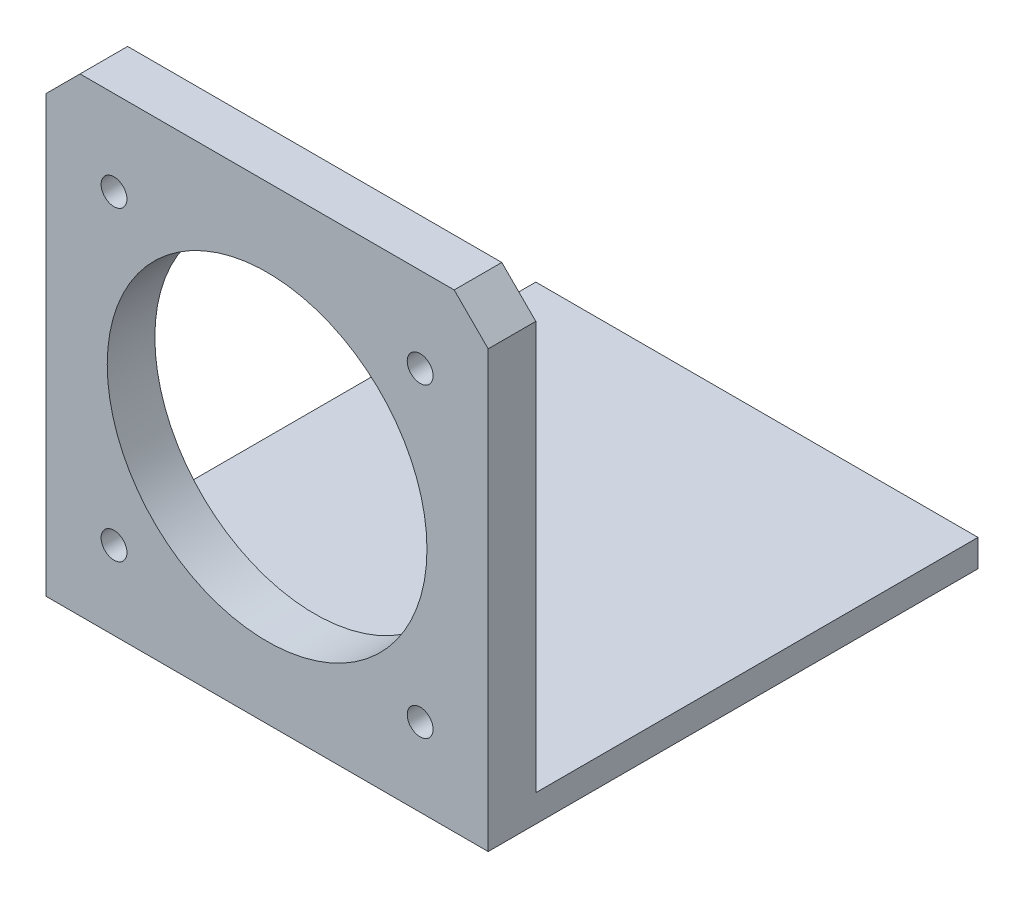
from build123d import *

# Parameters (mm, degrees)
BOSS_EXTRUDE1_DEPTH = 65
CHAMFER1_SIZE       = 5
SKETCH4_R           = 23.5
SKETCH4_R_2         = 1.9
CUT_EXTRUDE1_DEPTH  = 65


with BuildPart() as part:
    # Sketch2 → Boss-Extrude1 (new body)
    with BuildSketch(Plane(origin=(0, 0, 0), x_dir=(0, 0, -1), z_dir=(1, 0, 0))):
        Polygon((0, 0), (0, 65), (-7, 65), (-7, -4), (65, -4), (65, 0), align=None)
    extrude(amount=BOSS_EXTRUDE1_DEPTH)

    # Chamfer1
    chamfer1_edges = [part.edges().sort_by_distance(p)[0] for p in [
        (65, 65, 3.5),
        (0, 65, 3.5),
    ]]
    chamfer(chamfer1_edges, length=CHAMFER1_SIZE)

    # Sketch4 → Cut-Extrude1 (cut)
    with BuildSketch(Plane.XY.offset(7)):
        with Locations((32.5, 30)):
            Circle(SKETCH4_R)
        with Locations((10, 52.5)):
            Circle(SKETCH4_R_2)
        with Locations((55, 52.5)):
            Circle(SKETCH4_R_2)
        with Locations((55, 7.5)):
            Circle(SKETCH4_R_2)
        with Locations((10, 7.5)):
            Circle(SKETCH4_R_2)
    extrude(amount=-CUT_EXTRUDE1_DEPTH, mode=Mode.SUBTRACT)


solid = part.part
